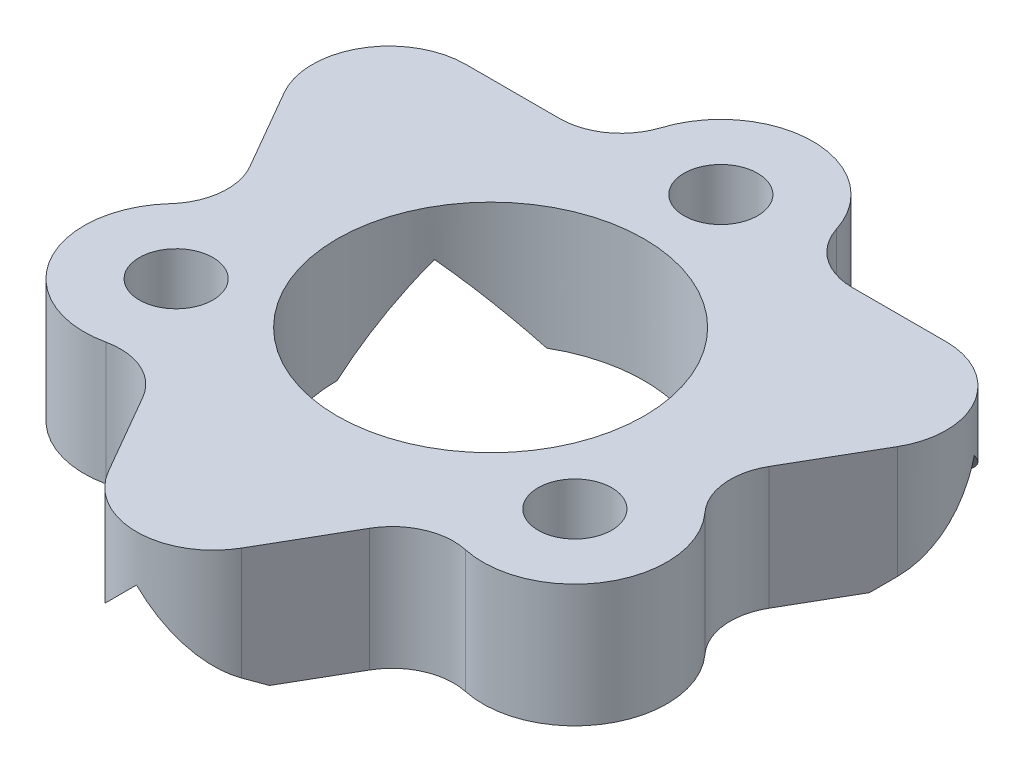
from build123d import *

# Parameters (mm, degrees)
SKETCH1_R                                       = 5
EXTRUDE1_DEPTH                                  = 4
CSK_FOR_M2_OVAL_HEAD_MACHINE_SCREW1_D           = 2.4
CSK_FOR_M2_OVAL_HEAD_MACHINE_SCREW1_CSINK_D     = 4.4
CSK_FOR_M2_OVAL_HEAD_MACHINE_SCREW1_CSINK_ANGLE = 90
CIRPATTERN2_COUNT                               = 3
EXTRUDE4_START                                  = 4.45086
EXTRUDE4_DEPTH                                  = 7.205259
EXTRUDE5_START                                  = 4.330127
EXTRUDE5_DEPTH                                  = 7.205258
EXTRUDE6_START                                  = 4.330127
EXTRUDE6_DEPTH                                  = 7.205258


with BuildPart() as part:
    # Sketch1 → Extrude1 (new body)
    with BuildSketch(Plane(origin=(0, 0, 0), x_dir=(1, 0, 0), z_dir=(0, 1, 0))):
        with BuildLine():
            Line((-3.89089061, 3.146959138), (-2.360502052, 0.4962484))
            ThreePointArc((-2.360502052, 0.4962484), (-2.104118872, -0.718531203), (-2.613989574, -1.850544314))
            ThreePointArc((-2.613989574, -1.850544314), (-2.994220859, -5.370733384), (0.244467944, -6.801537968))
            ThreePointArc((0.244467944, -6.801537968), (1.479755407, -6.925983542), (2.403593813, -7.75540769))
            Line((2.403593813, -7.75540769), (3.933982371, -10.406118428))
            ThreePointArc((3.933982371, -10.406118428), (6.099045881, -11.656118428), (8.26410939, -10.406118428))
            Line((8.26410939, -10.406118428), (9.794497948, -7.75540769))
            ThreePointArc((9.794497948, -7.75540769), (10.718336354, -6.925983542), (11.953623817, -6.801537968))
            ThreePointArc((11.953623817, -6.801537968), (15.192312621, -5.370733384), (14.812081336, -1.850544314))
            ThreePointArc((14.812081336, -1.850544314), (14.302210633, -0.718531203), (14.558593813, 0.4962484))
            Line((14.558593813, 0.4962484), (16.088982371, 3.146959138))
            ThreePointArc((16.088982371, 3.146959138), (16.088982371, 5.646959138), (13.923918862, 6.896959138))
            Line((13.923918862, 6.896959138), (10.863141746, 6.896959138))
            ThreePointArc((10.863141746, 6.896959138), (9.68292016, 7.282314592), (8.9575034, 8.289882129))
            ThreePointArc((8.9575034, 8.289882129), (6.099045881, 10.379266616), (3.240588362, 8.289882129))
            ThreePointArc((3.240588362, 8.289882129), (2.515171602, 7.282314592), (1.334950016, 6.896959138))
            Line((1.334950016, 6.896959138), (-1.7258271, 6.896959138))
            ThreePointArc((-1.7258271, 6.896959138), (-3.89089061, 5.646959138), (-3.89089061, 3.146959138))
        make_face()
        with Locations((6.099045881, -0.120733384)):
            Circle(SKETCH1_R, mode=Mode.SUBTRACT)
    extrude(amount=EXTRUDE1_DEPTH)

    # CSK for M2 Oval Head Machine Screw1 (through all)
    with Locations(Plane(origin=(-0.396144648, 0, 3.870733384), x_dir=(0, 0, -1), z_dir=(0, -1, 0))):
        with Locations((0, 0)):
            csk_for_m2_oval_head_machine_screw1 = CounterSinkHole(CSK_FOR_M2_OVAL_HEAD_MACHINE_SCREW1_D / 2, CSK_FOR_M2_OVAL_HEAD_MACHINE_SCREW1_CSINK_D / 2, counter_sink_angle=CSK_FOR_M2_OVAL_HEAD_MACHINE_SCREW1_CSINK_ANGLE)

    # CirPattern2: CSK for M2 Oval Head Machine Screw1 ×3 about axis
    cirpattern2_axis = Axis((6.099045881, 0, 0.120733384), (0, 1, 0))
    for i in range(1, CIRPATTERN2_COUNT):
        add(csk_for_m2_oval_head_machine_screw1.rotate(cirpattern2_axis, i * 360 / CIRPATTERN2_COUNT), mode=Mode.SUBTRACT)

    # GrooveSketch → Extrude4 (cut)
    with BuildSketch(Plane.XY.offset(EXTRUDE4_START)):
        Polygon((34.668922444, -26.069876563), (8.599045881, 0), (6.099045881, 2.5), (3.599045881, 0), (-22.470830682, -26.069876563), (-22.470830682, -99.806622573), (34.668922444, -99.806622573), align=None)
    extrude(amount=EXTRUDE4_DEPTH, mode=Mode.SUBTRACT)

    # Sketch9 → Extrude5 (cut)
    with BuildSketch(Plane(origin=(4.6265635, 0, 2.671147682), x_dir=(-0.5, 0, 0.866025404), z_dir=(-0.866025404, 0, -0.5)).offset(EXTRUDE5_START)):
        Polygon((32.223222882, -32.668187644), (-0.444964763, 0), (-2.944964763, 2.5), (-5.444964763, 0), (-38.113152407, -32.668187644), (-38.113152407, -125.067775694), (32.223222882, -125.067775694), align=None)
    extrude(amount=EXTRUDE5_DEPTH, mode=Mode.SUBTRACT)

    # Sketch10 → Extrude6 (cut)
    with BuildSketch(Plane(origin=(4.522005322, 0, -2.61078099), x_dir=(-0.5, 0, -0.866025404), z_dir=(0.866025404, 0, -0.5)).offset(EXTRUDE6_START)):
        Polygon((32.014106526, -32.668187644), (-0.654081118, 0), (-3.154081118, 2.5), (-5.654081118, 0), (-38.322268763, -32.668187644), (-38.322268763, -125.067775694), (32.014106526, -125.067775694), align=None)
    extrude(amount=EXTRUDE6_DEPTH, mode=Mode.SUBTRACT)


solid = part.part
